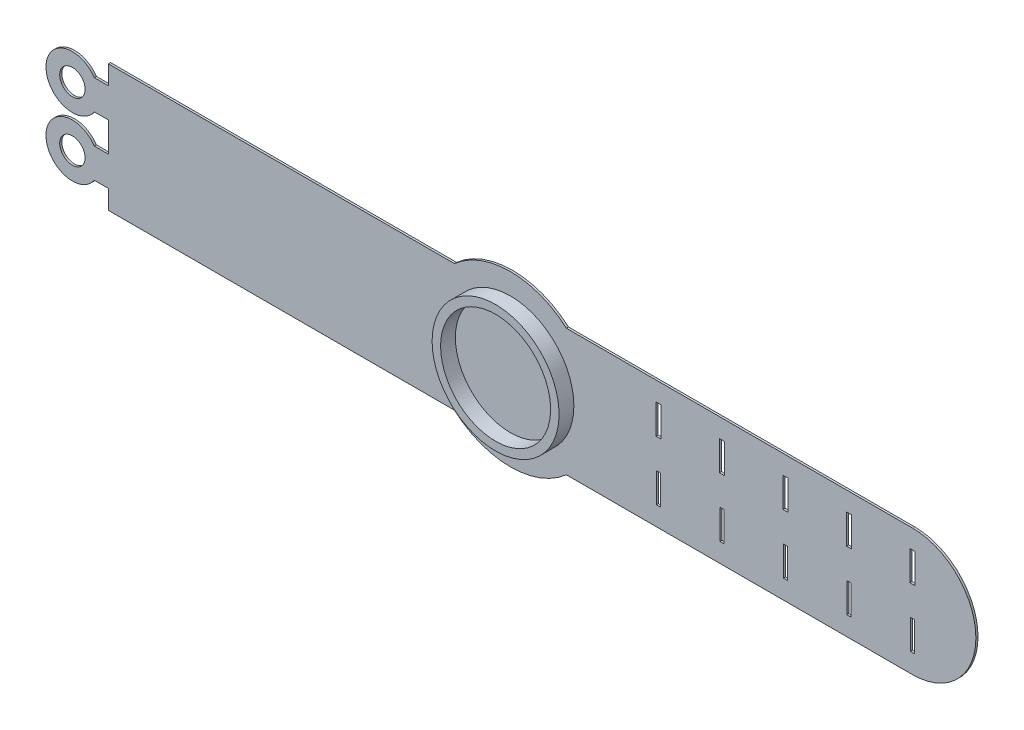
from build123d import *

# Parameters (mm, degrees)
SKETCH_1_W      = 1
SKETCH_1_H      = 7
SKETCH_1_W_2    = 1.2
SKETCH_1_R      = 3
EXTRUDE_2_DEPTH = 0.5
SKETCH_3_R      = 15
SKETCH_3_R_2    = 13
EXTRUDE_3_DEPTH = 4


with BuildPart() as part:
    # Эскиз1 → Бобышка-Вытянуть2 (new body)
    with BuildSketch(Plane.XY):
        with BuildLine():
            Line((95, 15), (13.228756555, 15))
            ThreePointArc((13.228756555, 15), (0, 20), (-13.228756555, 15))
            Line((-13.228756555, 15), (-95, 15))
            Line((-95, 15), (-95, 10.5))
            Line((-95, 10.5), (-98.321921206, 10.5))
            ThreePointArc((-98.321921206, 10.5), (-109.75, 7), (-98.321921206, 3.5))
            Line((-98.321921206, 3.5), (-95, 3.5))
            Line((-95, 3.5), (-95, -3.5))
            Line((-95, -3.5), (-98.321921206, -3.5))
            ThreePointArc((-98.321921206, -3.5), (-109.75, -7), (-98.321921206, -10.5))
            Line((-98.321921206, -10.5), (-95, -10.5))
            Line((-95, -10.5), (-95, -15))
            Line((-95, -15), (-13.228756555, -15))
            ThreePointArc((-13.228756555, -15), (0, -20), (13.228756555, -15))
            Line((13.228756555, -15), (95, -15))
            ThreePointArc((95, -15), (110, 0), (95, 15))
        make_face()
        with Locations((35, -7)):
            Rectangle(SKETCH_1_W, SKETCH_1_H, mode=Mode.SUBTRACT)
        with Locations((50, -7)):
            Rectangle(SKETCH_1_W, SKETCH_1_H, mode=Mode.SUBTRACT)
        with Locations((65, -7)):
            Rectangle(SKETCH_1_W, SKETCH_1_H, mode=Mode.SUBTRACT)
        with Locations((80, -7)):
            Rectangle(SKETCH_1_W, SKETCH_1_H, mode=Mode.SUBTRACT)
        with Locations((95, -7)):
            Rectangle(SKETCH_1_W, SKETCH_1_H, mode=Mode.SUBTRACT)
        with Locations((35, 7)):
            Rectangle(SKETCH_1_W_2, SKETCH_1_H, mode=Mode.SUBTRACT)
        with Locations((50, 7)):
            Rectangle(SKETCH_1_W_2, SKETCH_1_H, mode=Mode.SUBTRACT)
        with Locations((65, 7)):
            Rectangle(SKETCH_1_W_2, SKETCH_1_H, mode=Mode.SUBTRACT)
        with Locations((80, 7)):
            Rectangle(SKETCH_1_W_2, SKETCH_1_H, mode=Mode.SUBTRACT)
        with Locations((95, 7)):
            Rectangle(SKETCH_1_W_2, SKETCH_1_H, mode=Mode.SUBTRACT)
        with Locations((-103.5, 7)):
            Circle(SKETCH_1_R, mode=Mode.SUBTRACT)
        with Locations((-103.5, -7)):
            Circle(SKETCH_1_R, mode=Mode.SUBTRACT)
    extrude(amount=EXTRUDE_2_DEPTH)

    # Эскиз3 → Бобышка-Вытянуть3 (add)
    with BuildSketch(Plane(origin=(0, 0, 0), x_dir=(-1, 0, 0), z_dir=(0, 0, -1))):
        Circle(SKETCH_3_R)
        Circle(SKETCH_3_R_2, mode=Mode.SUBTRACT)
    extrude(amount=-EXTRUDE_3_DEPTH)


solid = part.part
